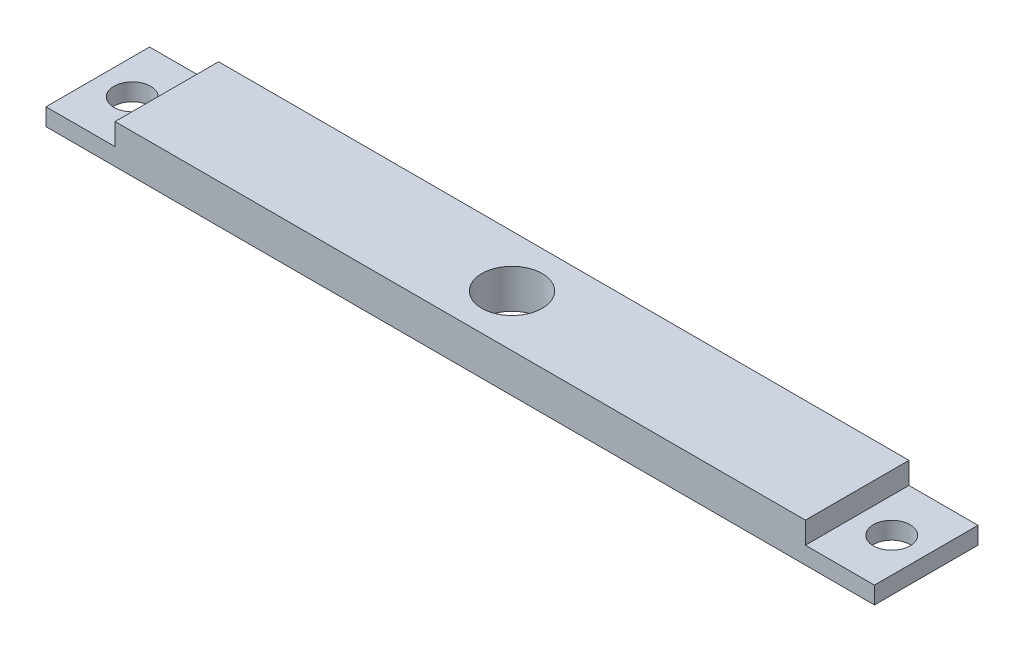
from build123d import *

# Parameters (mm, degrees)
BOSS_EXTRUDE1_DEPTH = 19.05
SKETCH2_R           = 5.55625
CUT_EXTRUDE1_DEPTH  = 8.1755
SKETCH3_R           = 3.3782
CUT_EXTRUDE2_DEPTH  = 4.175


with BuildPart() as part:
    # Sketch1 → Boss-Extrude1 (new body)
    with BuildSketch(Plane.XY):
        Polygon((-76.2, 0), (76.2, 0), (76.2, 3.175), (63.5, 3.175), (63.5, 7.1755), (-63.5, 7.1755), (-63.5, 3.175), (-76.2, 3.175), align=None)
    extrude(amount=BOSS_EXTRUDE1_DEPTH)

    # Sketch2 → Cut-Extrude1 (cut, through all)
    with BuildSketch(Plane(origin=(0, 7.1755, 0), x_dir=(1, 0, 0), z_dir=(0, 1, 0))):
        with Locations((0, -9.525)):
            Circle(SKETCH2_R)
    extrude(amount=-CUT_EXTRUDE1_DEPTH, mode=Mode.SUBTRACT)

    # Sketch3 → Cut-Extrude2 (cut, through all)
    with BuildSketch(Plane(origin=(0, 3.175, 0), x_dir=(1, 0, 0), z_dir=(0, 1, 0))):
        with Locations((-69.85, -9.525)):
            Circle(SKETCH3_R)
        with Locations((69.85, -9.525)):
            Circle(SKETCH3_R)
    extrude(amount=-CUT_EXTRUDE2_DEPTH, mode=Mode.SUBTRACT)


solid = part.part
